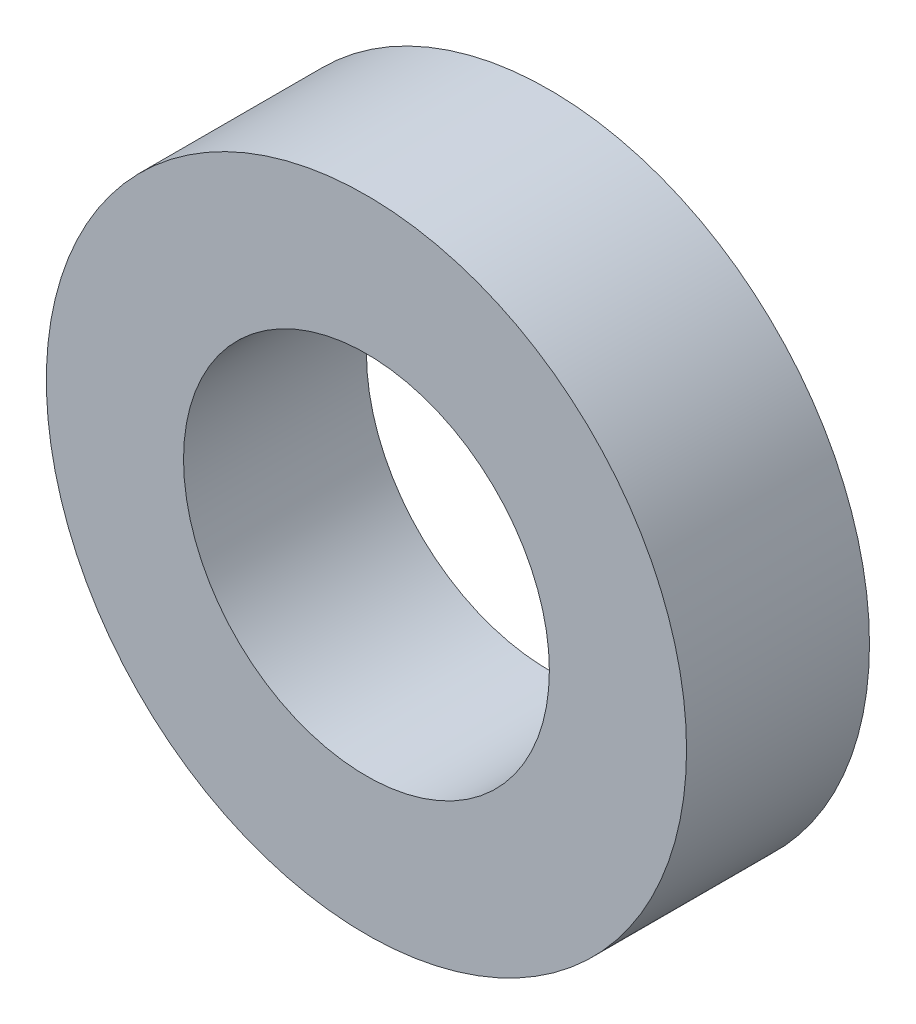
from build123d import *

# Parameters (mm, degrees)
SKETCH_1_R      = 7
SKETCH_1_R_2    = 4
EXTRUDE_1_DEPTH = 2


with BuildPart() as part:
    # 草图1 → 凸台-拉伸1 (new body, symmetric)
    with BuildSketch(Plane.XY):
        Circle(SKETCH_1_R)
        Circle(SKETCH_1_R_2, mode=Mode.SUBTRACT)
    extrude(amount=EXTRUDE_1_DEPTH, both=True)


solid = part.part
